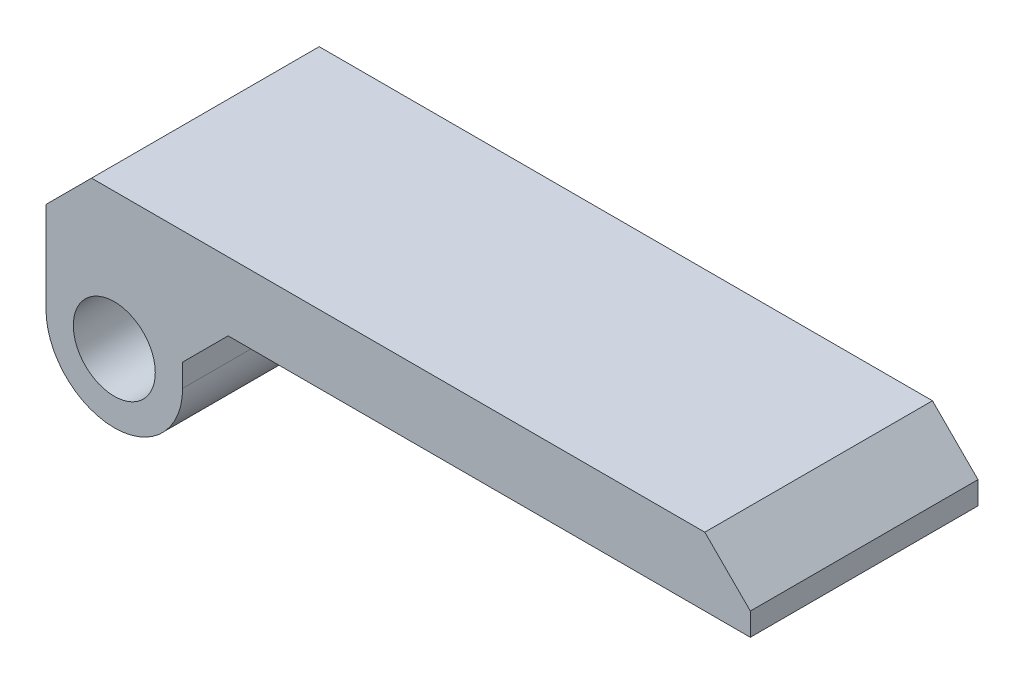
from build123d import *

# Parameters (mm, degrees)
SKETCH1_W           = 120
SKETCH1_H           = 60
BOSS_EXTRUDE1_DEPTH = 2
CHAMFER2_SIZE       = 10
SKETCH2_W           = 38.34314575
SKETCH2_H           = 2
BOSS_EXTRUDE2_DEPTH = 15
FILLET1_R           = 2
SKETCH4_R           = 2.5
SKETCH4_R_2         = 1
BOSS_EXTRUDE3_DEPTH = 4
SKETCH6_W           = 61
SKETCH6_H           = 14.6
BOSS_EXTRUDE5_DEPTH = 15
CUT_EXTRUDE2_START  = -3
CUT_EXTRUDE2_DEPTH  = 55
CHAMFER3_SIZE       = 4
SKETCH9_W           = 14
SKETCH9_H           = 16
SKETCH9_W_2         = 10
SKETCH9_H_2         = 12
BOSS_EXTRUDE6_DEPTH = 4
SKETCH10_R          = 3
SKETCH10_R_2        = 1.5
BOSS_EXTRUDE8_DEPTH = 4
BOSS_EXTRUDE9_START = 10
SKETCH12_R          = 3
SKETCH12_R_2        = 1.8
BOSS_EXTRUDE9_DEPTH = 10
CHAMFER4_SIZE       = 2
SKETCH13_W          = 142.36375675
SKETCH13_H          = 36.547684865
CUT_EXTRUDE3_DEPTH  = 85
CUT_EXTRUDE4_START  = -4
CUT_EXTRUDE4_DEPTH  = 2


with BuildPart() as part:
    # Sketch1 → Boss-Extrude1 (new body)
    with BuildSketch(Plane.XY):
        with Locations((60, 30)):
            Rectangle(SKETCH1_W, SKETCH1_H)
    extrude(amount=BOSS_EXTRUDE1_DEPTH)

    # Chamfer2
    chamfer2_edges = [part.edges().sort_by_distance(p)[0] for p in [
        (0, 60, 1),
        (120, 60, 1),
        (120, 0, 1),
        (0, 0, 1),
    ]]
    chamfer(chamfer2_edges, length=CHAMFER2_SIZE)

    # Sketch2 → Boss-Extrude2 (add)
    with BuildSketch(Plane.XY.offset(2)):
        Polygon((10.828427125, 2), (109.171572875, 2), (118, 10.828427125), (118, 49.171572875), (109.171572875, 58), (109.171572875, 60), (110, 60), (120, 50), (120, 10), (110, 0), (10, 0), (0, 10), (0, 50), (10, 60), (10.828427125, 60), (10.828427125, 58), (2, 49.171572875), (2, 10.828427125), align=None)
        with Locations((60, 59)):
            Rectangle(SKETCH2_W, SKETCH2_H)
    extrude(amount=BOSS_EXTRUDE2_DEPTH)

    # Fillet1
    fillet1_edges = [part.edges().sort_by_distance(p)[0] for p in [
        (113.585786438, 53.585786438, 2),
        (118, 30, 2),
        (113.585786438, 6.414213562, 2),
        (60, 2, 2),
        (6.414213562, 6.414213562, 2),
        (2, 30, 2),
        (6.414213562, 53.585786438, 2),
        (60, 58, 2),
    ]]
    fillet(fillet1_edges, radius=FILLET1_R)

    # Sketch4 → Boss-Extrude3 (add)
    with BuildSketch(Plane.XY.offset(2)):
        with Locations((33, 41)):
            Circle(SKETCH4_R)
        with Locations((33, 41)):
            Circle(SKETCH4_R_2, mode=Mode.SUBTRACT)
    extrude(amount=BOSS_EXTRUDE3_DEPTH)

    # Sketch6 → Boss-Extrude5 (add)
    with BuildSketch(Plane.XY.offset(2)):
        with Locations((60, 9.3)):
            Rectangle(SKETCH6_W, SKETCH6_H)
    extrude(amount=BOSS_EXTRUDE5_DEPTH)

    # Sketch7 → Cut-Extrude2 (cut)
    with BuildSketch(Plane.ZY.offset(-29.5).offset(CUT_EXTRUDE2_START)):
        with BuildLine():
            ThreePointArc((16.8, 9.3), (14.661879503, 14.461879503), (9.5, 16.6))
            Line((9.5, 16.6), (9.5, 2))
            ThreePointArc((9.5, 2), (14.661879503, 4.138120497), (16.8, 9.3))
        make_face()
        with BuildLine():
            Line((9.5, 2), (9.5, 16.6))
            ThreePointArc((9.5, 16.6), (2.2, 9.3), (9.5, 2))
        make_face()
        with BuildLine():
            Line((17, 16.6), (9.5, 16.6))
            ThreePointArc((9.5, 16.6), (14.661879503, 14.461879503), (16.8, 9.3))
            ThreePointArc((16.8, 9.3), (14.661879503, 4.138120497), (9.5, 2))
            Line((9.5, 2), (17, 2))
            Line((17, 2), (17, 16.6))
        make_face()
    extrude(amount=-CUT_EXTRUDE2_DEPTH, mode=Mode.SUBTRACT)

    # Chamfer3
    chamfer3_edges = [part.edges().sort_by_distance(p)[0] for p in [
        (31, 16.6, 17),
        (89, 16.6, 17),
    ]]
    chamfer(chamfer3_edges, length=CHAMFER3_SIZE)

    # Sketch9 → Boss-Extrude6 (add)
    with BuildSketch(Plane.XY.offset(2)):
        with Locations((45, 41)):
            Rectangle(SKETCH9_W, SKETCH9_H)
        with Locations((45, 41)):
            Rectangle(SKETCH9_W_2, SKETCH9_H_2, mode=Mode.SUBTRACT)
    extrude(amount=BOSS_EXTRUDE6_DEPTH)

    # Sketch10 → Boss-Extrude8 (add)
    with BuildSketch(Plane.XY.offset(2)):
        with Locations((14.828427125, 57)):
            Circle(SKETCH10_R)
        with Locations((14.828427125, 57)):
            Circle(SKETCH10_R_2, mode=Mode.SUBTRACT)
        with Locations((105.171572875, 57)):
            Circle(SKETCH10_R)
        with Locations((105.171572875, 57)):
            Circle(SKETCH10_R_2, mode=Mode.SUBTRACT)
    extrude(amount=BOSS_EXTRUDE8_DEPTH)

    # Sketch13 → Cut-Extrude3 (cut)
    with BuildSketch(Plane(origin=(0, 60, 0), x_dir=(1, 0, 0), z_dir=(0, 1, 0))):
        with Locations((60.382698271, -6.82770274)):
            Rectangle(SKETCH13_W, SKETCH13_H)
    extrude(amount=-CUT_EXTRUDE3_DEPTH, mode=Mode.SUBTRACT)


with BuildPart() as body_2:
    # Sketch12 → Boss-Extrude9 (new body)
    with BuildSketch(Plane.XY.offset(17).offset(BOSS_EXTRUDE9_START)):
        with Locations((14.828427125, 57)):
            Circle(SKETCH12_R)
        with Locations((14.828427125, 57)):
            Circle(SKETCH12_R_2, mode=Mode.SUBTRACT)
        with BuildLine():
            Line((11.828427125, 63), (11.828427125, 57))
            ThreePointArc((11.828427125, 57), (14.828427125, 60), (17.828427125, 57))
            Line((17.828427125, 57), (17.828427125, 60))
            Line((17.828427125, 60), (42.76580882, 60))
            Line((42.76580882, 60), (42.76580882, 63))
            Line((42.76580882, 63), (11.828427125, 63))
        make_face()
    extrude(amount=BOSS_EXTRUDE9_DEPTH)

    # Chamfer4
    chamfer4_edges = [body_2.edges().sort_by_distance(p)[0] for p in [
        (11.828427125, 63, 32),
        (42.76580882, 63, 32),
        (17.828427125, 60, 32),
    ]]
    chamfer(chamfer4_edges, length=CHAMFER4_SIZE)

    # Sketch14 → Cut-Extrude4 (cut)
    with BuildSketch(Plane.XY.offset(37).offset(CUT_EXTRUDE4_START)):
        Polygon((32.828427125, 60), (32.828427125, 61.5), (17.828427125, 61.5), (17.828427125, 58), (28.911209964, 56.857462596), align=None)
    extrude(amount=-CUT_EXTRUDE4_DEPTH, mode=Mode.SUBTRACT)


solid = body_2.part
